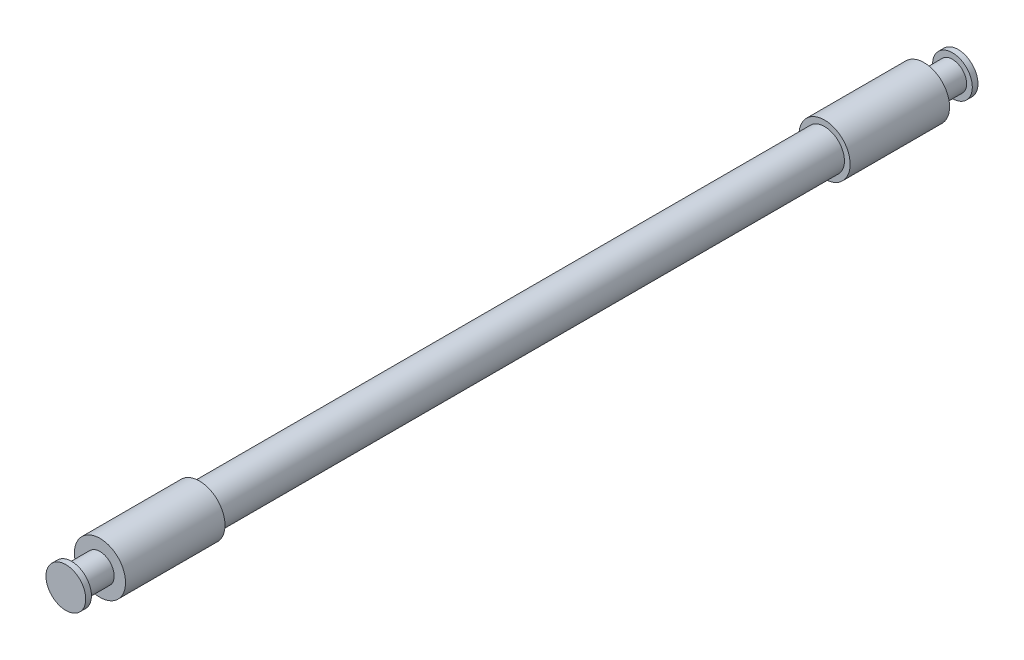
from build123d import *


with BuildPart() as part:
    # Sketch1 → Revolve2 (revolve)
    with BuildSketch(Plane(origin=(0, 0, 0), x_dir=(1, 0, 0), z_dir=(0, 1, 0))):
        Polygon((0, -199.39), (8.89, -199.39), (8.89, -196.85), (6.35, -196.85), (6.35, -184.15), (11.43, -184.15), (11.43, -139.7), (8.89, -139.7), (8.89, 139.7), (11.43, 139.7), (11.43, 184.15), (6.35, 184.15), (6.35, 196.85), (8.89, 196.85), (8.89, 199.39), (0, 199.39), align=None)
    revolve(axis=Axis((0, 0, 199.39), (0, 0, -1)))


solid = part.part
